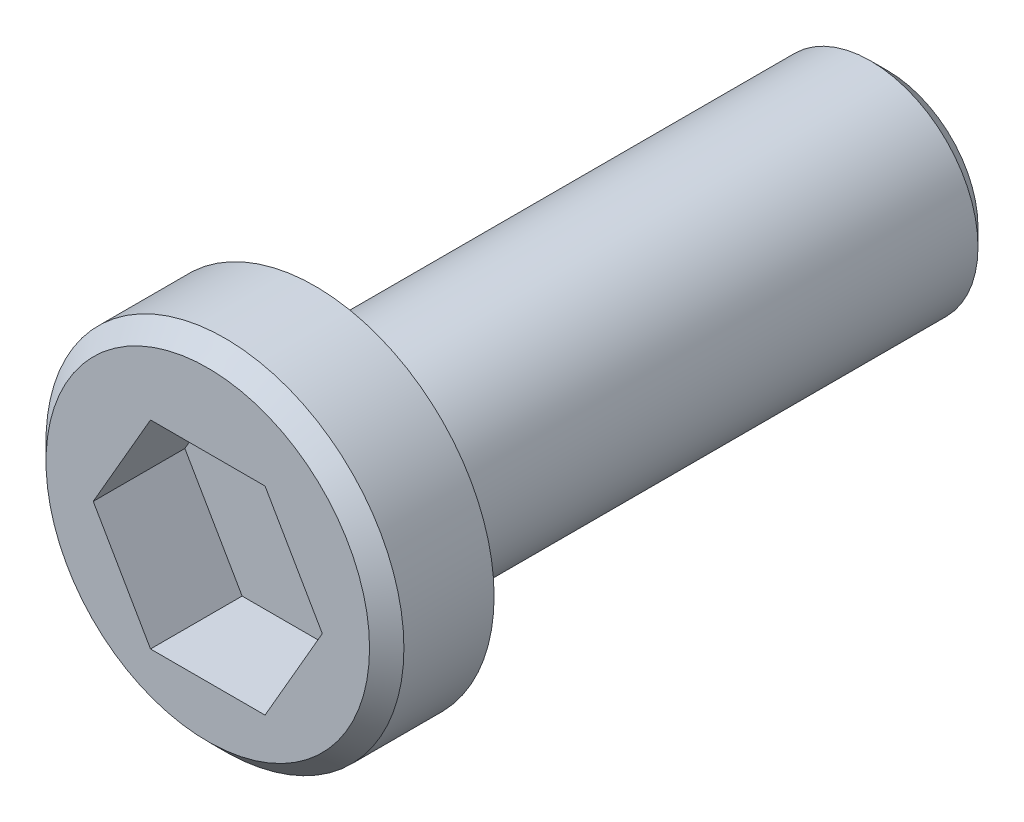
from build123d import *

# Parameters (mm, degrees)
SKETCH1_R          = 4.7625
EXTRUDE1_DEPTH     = 25.4
SKETCH3_R          = 7.9375
EXTRUDE3_DEPTH     = 4.7625
CHAMFER1_SIZE      = 0.762
CUT_EXTRUDE1_DEPTH = 4.064


with BuildPart() as part:
    # Sketch1 → Extrude1 (new body)
    with BuildSketch(Plane.XY):
        Circle(SKETCH1_R)
    extrude(amount=EXTRUDE1_DEPTH)

    # Sketch3 → Extrude3 (add)
    with BuildSketch(Plane.XY.offset(25.4)):
        with Locations((0, 0.491553118)):
            Circle(SKETCH3_R)
    extrude(amount=EXTRUDE3_DEPTH)

    # Chamfer1
    chamfer1_edges = [part.edges().sort_by_distance(p)[0] for p in [
        (-4.7625, 0, 0),
        (-7.9375, 0.491553118, 30.1625),
    ]]
    chamfer(chamfer1_edges, length=CHAMFER1_SIZE)

    # Sketch4 → Cut-Extrude1 (cut)
    with BuildSketch(Plane.XY.offset(30.1625)):
        Polygon((5.08, 0), (2.54, 4.399409051), (-2.54, 4.399409051), (-5.08, 0), (-2.54, -4.399409051), (2.54, -4.399409051), align=None)
    extrude(amount=-CUT_EXTRUDE1_DEPTH, mode=Mode.SUBTRACT)


solid = part.part
